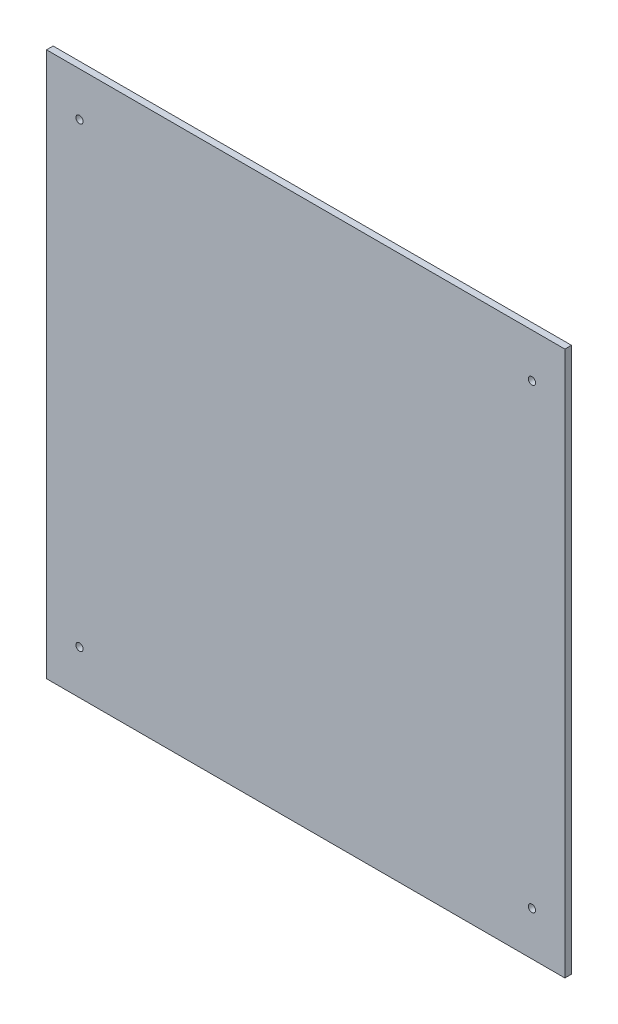
from build123d import *

# Parameters (mm, degrees)
ESQUISSE1_W             = 236
ESQUISSE1_H             = 248
BOSS_EXTRU_1_DEPTH      = 3
ESQUISSE2_R             = 1.65
ENL_V_MAT_EXTRU_1_DEPTH = 4


with BuildPart() as part:
    # Esquisse1 → Boss.-Extru.1 (new body)
    with BuildSketch(Plane.XY):
        with Locations((118, 124)):
            Rectangle(ESQUISSE1_W, ESQUISSE1_H)
    extrude(amount=BOSS_EXTRU_1_DEPTH)

    # Esquisse2 → Enlèv. mat.-Extru.1 (cut, through all)
    with BuildSketch(Plane.XY.offset(3)):
        with Locations((15, 228)):
            Circle(ESQUISSE2_R)
        with Locations((221, 228)):
            Circle(ESQUISSE2_R)
        with Locations((221, 20)):
            Circle(ESQUISSE2_R)
        with Locations((15, 20)):
            Circle(ESQUISSE2_R)
    extrude(amount=-ENL_V_MAT_EXTRU_1_DEPTH, mode=Mode.SUBTRACT)


solid = part.part
